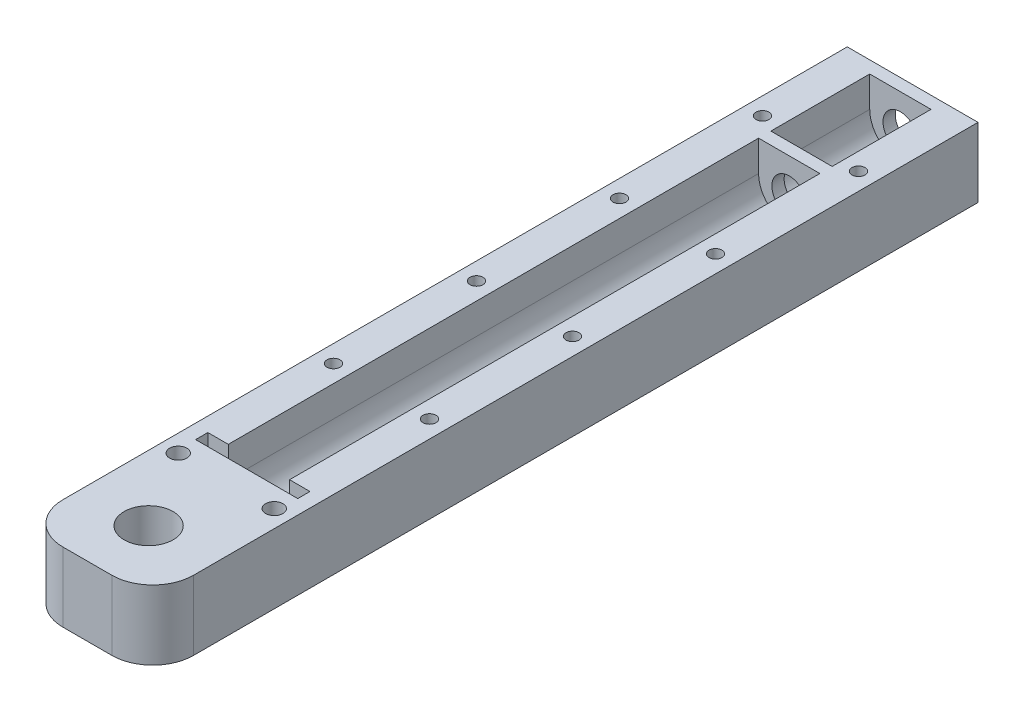
from build123d import *

# Parameters (mm, degrees)
SKETCH1_W           = 32
SKETCH1_H           = 17
SKETCH1_R           = 4.25
BOSS_EXTRUDE1_DEPTH = 3
BOSS_EXTRUDE2_DEPTH = 24.2
SKETCH3_W           = 32
SKETCH3_H           = 17
SKETCH3_R           = 4.25
BOSS_EXTRUDE3_DEPTH = 3
BOSS_EXTRUDE4_DEPTH = 129.8
SKETCH5_W           = 32
SKETCH5_H           = 17
BOSS_EXTRUDE5_DEPTH = 18
SKETCH6_W           = 25
SKETCH6_H           = 3
CUT_EXTRUDE1_DEPTH  = 15
BOSS_EXTRUDE6_DEPTH = 17
SKETCH8_R           = 6
CUT_EXTRUDE2_DEPTH  = 46
SKETCH9_R           = 1.5875
SKETCH9_R_2         = 2.114349704
CUT_EXTRUDE3_DEPTH  = 46
SKETCH10_R          = 1.5875
SKETCH10_R_2        = 2.114349704
CUT_EXTRUDE4_DEPTH  = 4


with BuildPart() as part:
    # Sketch1 → Boss-Extrude1 (new body)
    with BuildSketch(Plane.XY):
        Rectangle(SKETCH1_W, SKETCH1_H)
        Circle(SKETCH1_R, mode=Mode.SUBTRACT)
    extrude(amount=BOSS_EXTRUDE1_DEPTH)

    # Sketch2 → Boss-Extrude2 (add)
    with BuildSketch(Plane.XY.offset(3)):
        with BuildLine():
            Line((-7.5, 1), (-7.5, 8.5))
            Line((-7.5, 8.5), (-16, 8.5))
            Line((-16, 8.5), (-16, -8.5))
            Line((-16, -8.5), (16, -8.5))
            Line((16, -8.5), (16, 8.5))
            Line((16, 8.5), (7.5, 8.5))
            Line((7.5, 8.5), (7.5, 1))
            ThreePointArc((7.5, 1), (0, -6.5), (-7.5, 1))
        make_face()
    extrude(amount=BOSS_EXTRUDE2_DEPTH)

    # Sketch3 → Boss-Extrude3 (add)
    with BuildSketch(Plane.XY.offset(27.2)):
        Rectangle(SKETCH3_W, SKETCH3_H)
        Circle(SKETCH3_R, mode=Mode.SUBTRACT)
    extrude(amount=BOSS_EXTRUDE3_DEPTH)

    # Sketch4 → Boss-Extrude4 (add)
    with BuildSketch(Plane.XY.offset(30.2)):
        with BuildLine():
            Line((16, -8.5), (-16, -8.5))
            Line((-16, -8.5), (-16, 8.5))
            Line((-16, 8.5), (-7.5, 8.5))
            Line((-7.5, 8.5), (-7.5, 1))
            ThreePointArc((-7.5, 1), (0, -6.5), (7.5, 1))
            Line((7.5, 1), (7.5, 8.5))
            Line((7.5, 8.5), (16, 8.5))
            Line((16, 8.5), (16, -8.5))
        make_face()
    extrude(amount=BOSS_EXTRUDE4_DEPTH)

    # Sketch5 → Boss-Extrude5 (add)
    with BuildSketch(Plane.XY.offset(160)):
        Rectangle(SKETCH5_W, SKETCH5_H)
    extrude(amount=BOSS_EXTRUDE5_DEPTH)

    # Sketch6 → Cut-Extrude1 (cut)
    with BuildSketch(Plane(origin=(0, 8.5, 0), x_dir=(1, 0, 0), z_dir=(0, 1, 0))):
        with Locations((0, -161.5)):
            Rectangle(SKETCH6_W, SKETCH6_H)
    extrude(amount=-CUT_EXTRUDE1_DEPTH, mode=Mode.SUBTRACT)

    # Sketch7 → Boss-Extrude6 (add)
    with BuildSketch(Plane(origin=(0, 8.5, 0), x_dir=(1, 0, 0), z_dir=(0, 1, 0))):
        with BuildLine():
            Line((-16, -178), (16, -178))
            Line((16, -178), (16, -192))
            ThreePointArc((16, -192), (13.071067812, -199.071067812), (6, -202))
            Line((6, -202), (-6, -202))
            ThreePointArc((-6, -202), (-13.071067812, -199.071067812), (-16, -192))
            Line((-16, -192), (-16, -178))
        make_face()
    extrude(amount=-BOSS_EXTRUDE6_DEPTH)

    # Sketch8 → Cut-Extrude2 (cut)
    with BuildSketch(Plane(origin=(0, 8.5, 0), x_dir=(1, 0, 0), z_dir=(0, 1, 0))):
        with Locations((0, -187)):
            Circle(SKETCH8_R)
    extrude(amount=-CUT_EXTRUDE2_DEPTH, mode=Mode.SUBTRACT)

    # Sketch9 → Cut-Extrude3 (cut)
    with BuildSketch(Plane(origin=(0, 8.5, 0), x_dir=(1, 0, 0), z_dir=(0, 1, 0))):
        with Locations((11.75, -130)):
            Circle(SKETCH9_R)
        with Locations((-11.75, -130)):
            Circle(SKETCH9_R)
        with Locations((11.75, -95)):
            Circle(SKETCH9_R)
        with Locations((-11.75, -95)):
            Circle(SKETCH9_R)
        with Locations((11.75, -60)):
            Circle(SKETCH9_R)
        with Locations((11.75, -25)):
            Circle(SKETCH9_R)
        with Locations((-11.75, -25)):
            Circle(SKETCH9_R)
        with Locations((-11.75, -60)):
            Circle(SKETCH9_R)
        with Locations((11.75, -168)):
            Circle(SKETCH9_R_2)
        with Locations((-11.75, -168)):
            Circle(SKETCH9_R_2)
    extrude(amount=-CUT_EXTRUDE3_DEPTH, mode=Mode.SUBTRACT)

    # Sketch10 → Cut-Extrude4 (cut)
    with BuildSketch(Plane.XZ.offset(8.5)):
        Polygon((-15.214, 25), (-13.482, 22), (-10.018, 22), (-8.286, 25), (-10.018, 28), (-13.482, 28), align=None)
        with Locations((-11.75, 25)):
            Circle(SKETCH10_R, mode=Mode.SUBTRACT)
        Polygon((13.482, 28), (10.018, 28), (8.286, 25), (10.018, 22), (13.482, 22), (15.214, 25), align=None)
        with Locations((11.75, 25)):
            Circle(SKETCH10_R, mode=Mode.SUBTRACT)
        Polygon((13.482, 171.283743046), (10.018, 171.283743046), (8.286, 168.283743046), (10.018, 165.283743046), (13.482, 165.283743046), (15.214, 168.283743046), align=None)
        with Locations((11.75, 168)):
            Circle(SKETCH10_R_2, mode=Mode.SUBTRACT)
        Polygon((-10.017949192, 57), (-8.285898385, 60), (-10.017949192, 63), (-13.482050808, 63), (-15.214101615, 60), (-13.482050808, 57), align=None)
        with Locations((-11.75, 60)):
            Circle(SKETCH10_R, mode=Mode.SUBTRACT)
        Polygon((13.482050808, 57), (15.214101615, 60), (13.482050808, 63), (10.017949192, 63), (8.285898385, 60), (10.017949192, 57), align=None)
        with Locations((11.75, 60)):
            Circle(SKETCH10_R, mode=Mode.SUBTRACT)
        Polygon((13.482050808, 92), (15.214101615, 95), (13.482050808, 98), (10.017949192, 98), (8.285898385, 95), (10.017949192, 92), align=None)
        with Locations((11.75, 95)):
            Circle(SKETCH10_R, mode=Mode.SUBTRACT)
        Polygon((-10.017949192, 92), (-8.285898385, 95), (-10.017949192, 98), (-13.482050808, 98), (-15.214101615, 95), (-13.482050808, 92), align=None)
        with Locations((-11.75, 95)):
            Circle(SKETCH10_R, mode=Mode.SUBTRACT)
        Polygon((-10.017949192, 127.2), (-8.285898385, 130.2), (-10.017949192, 133.2), (-13.482050808, 133.2), (-15.214101615, 130.2), (-13.482050808, 127.2), align=None)
        Polygon((-10.017949192, 165), (-8.285898385, 168), (-10.017949192, 171), (-13.482050808, 171), (-15.214101615, 168), (-13.482050808, 165), align=None)
        with Locations((-11.75, 168)):
            Circle(SKETCH10_R_2, mode=Mode.SUBTRACT)
        Polygon((10.04912113, 127.250391955), (13.280790983, 127.152191667), (14.981669853, 129.901799713), (13.45087887, 132.749608045), (10.219209017, 132.847808333), (8.518330147, 130.098200287), align=None)
    extrude(amount=-CUT_EXTRUDE4_DEPTH, mode=Mode.SUBTRACT)


solid = part.part
